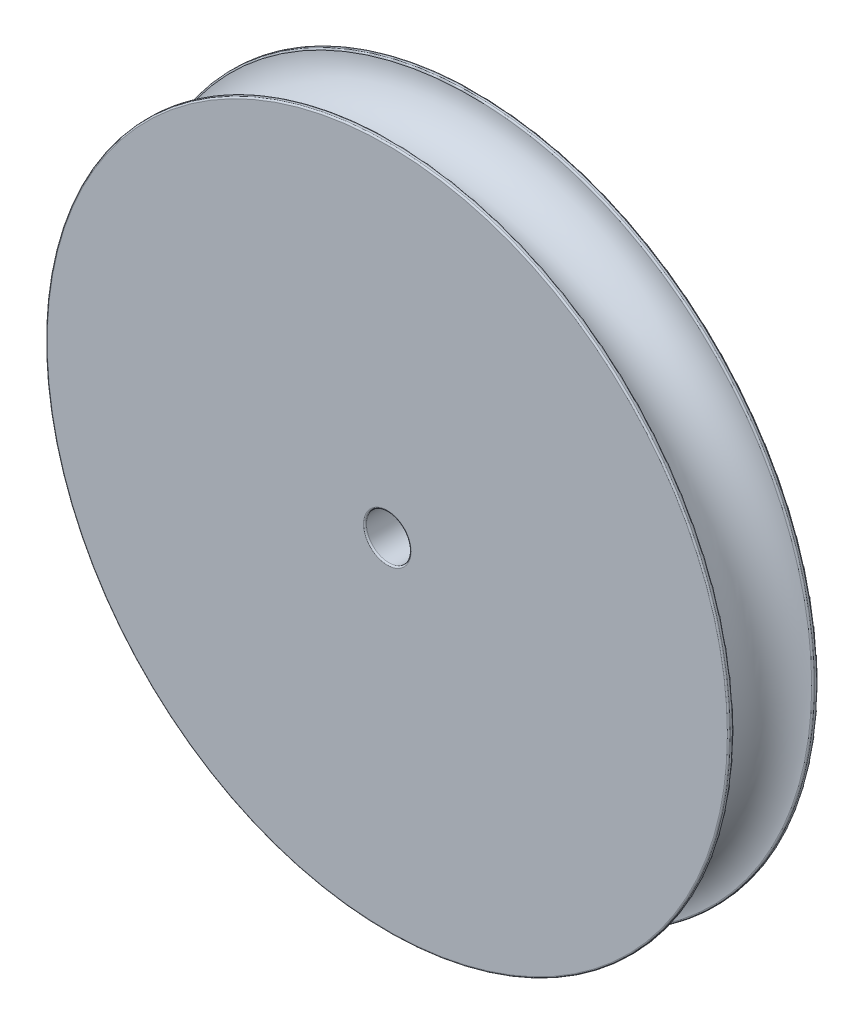
from build123d import *

# Parameters (mm, degrees)
ESQUISSE1_R             = 22.98
BOSS_EXTRU_2_DEPTH      = 3
ESQUISSE6_R             = 2.67
ESQUISSE7_R             = 6.5
BOSS_EXTRU_3_DEPTH      = 13
ESQUISSE8_R             = 1.5
ENL_V_MAT_EXTRU_1_DEPTH = 15
ESQUISSE10_R            = 1.5
ENL_V_MAT_EXTRU_2_DEPTH = 10
CONG_1_R                = 1
CONG_2_R                = 1
CONG_3_R                = 0.1
CONG_4_R                = 0.1
CONG_5_R                = 0.1
CONG_6_R                = 0.1
CONG_7_R                = 0.1
CONG_8_R                = 0.1
CONG_9_R                = 0.1


with BuildPart() as part:
    # Esquisse1 → Boss.-Extru.2 (new, symmetric)
    with BuildSketch(Plane.XY):
        Circle(ESQUISSE1_R)
    extrude(amount=BOSS_EXTRU_2_DEPTH, both=True)

    # Esquisse6 → Enlèvement de matière-Révolution1 (revolve, cut)
    with BuildSketch(Plane(origin=(0, 0, 0), x_dir=(1, 0, 0), z_dir=(0, 1, 0)), mode=Mode.PRIVATE) as enl_vement_de_mati_re_r_volution1_sk:
        with Locations((-22.98, 0)):
            Circle(ESQUISSE6_R)
    revolve(enl_vement_de_mati_re_r_volution1_sk.sketch.rotate(Axis((0, 0, 3), (0, 0, -1)), 180), axis=Axis((0, 0, 3), (0, 0, -1)), mode=Mode.SUBTRACT)

    # Esquisse7 → Boss.-Extru.3 (add)
    with BuildSketch(Plane.XY):
        Circle(ESQUISSE7_R)
    extrude(amount=-BOSS_EXTRU_3_DEPTH)

    # Esquisse8 → Enlèv. mat.-Extru.1 (cut, symmetric)
    with BuildSketch(Plane.XY):
        Circle(ESQUISSE8_R)
    extrude(amount=ENL_V_MAT_EXTRU_1_DEPTH, both=True, mode=Mode.SUBTRACT)

    # Esquisse10 → Enlèv. mat.-Extru.2 (cut)
    with BuildSketch(Plane(origin=(0, 0, 0), x_dir=(0, 0, -1), z_dir=(1, 0, 0))):
        with Locations((8.5, 0)):
            Circle(ESQUISSE10_R)
    extrude(amount=-ENL_V_MAT_EXTRU_2_DEPTH, mode=Mode.SUBTRACT)

    # Congé1
    cong_1_edges = [part.edges().sort_by_distance(p)[0] for p in [
        (-6.5, 0, -13),
    ]]
    fillet(cong_1_edges, radius=CONG_1_R)

    # Congé2
    cong_2_edges = [part.edges().sort_by_distance(p)[0] for p in [
        (-6.5, 0, -3),
    ]]
    fillet(cong_2_edges, radius=CONG_2_R)

    # Congé3
    cong_3_edges = [part.edges().sort_by_distance(p)[0] for p in [
        (-22.98, 0, -3),
    ]]
    fillet(cong_3_edges, radius=CONG_3_R)

    # Congé4
    cong_4_edges = [part.edges().sort_by_distance(p)[0] for p in [
        (-22.98, 0, -2.67),
    ]]
    fillet(cong_4_edges, radius=CONG_4_R)

    # Congé5
    cong_5_edges = [part.edges().sort_by_distance(p)[0] for p in [
        (-22.98, 0, 2.67),
    ]]
    fillet(cong_5_edges, radius=CONG_5_R)

    # Congé6
    cong_6_edges = [part.edges().sort_by_distance(p)[0] for p in [
        (-22.98, 0, 3),
    ]]
    fillet(cong_6_edges, radius=CONG_6_R)

    # Congé7
    cong_7_edges = [part.edges().sort_by_distance(p)[0] for p in [
        (-1.5, 0, 3),
    ]]
    fillet(cong_7_edges, radius=CONG_7_R)

    # Congé8
    cong_8_edges = [part.edges().sort_by_distance(p)[0] for p in [
        (-1.5, 0, -13),
    ]]
    fillet(cong_8_edges, radius=CONG_8_R)

    # Congé9
    cong_9_edges = [part.edges().sort_by_distance(p)[0] for p in [
        (-6.5, 0, -7),
    ]]
    fillet(cong_9_edges, radius=CONG_9_R)


solid = part.part
